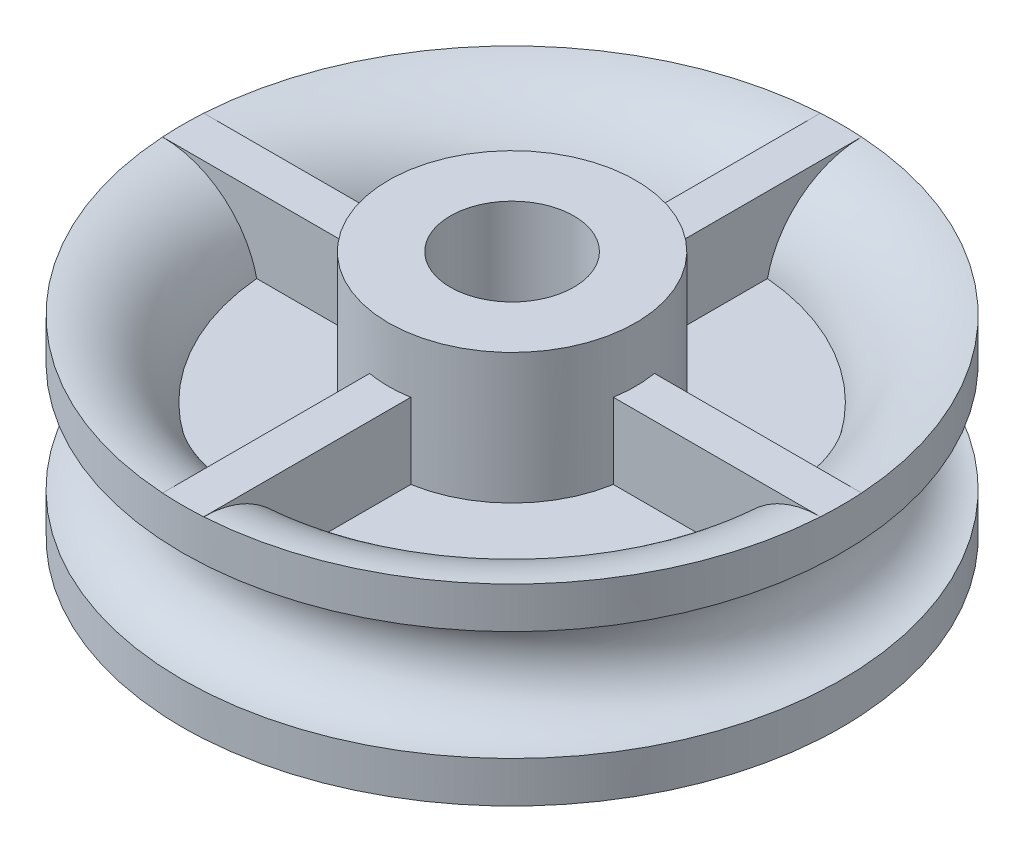
from build123d import *

# Parameters (mm, degrees)
RIB9_REACH        = 80.502
SKETCH5_WALL_W    = 189.003354934
SKETCH5_WALL_H    = 6
CIRPATTERN1_COUNT = 4


with BuildPart() as part:
    # Sketch1 → Revolve2 (revolve)
    with BuildSketch(Plane.XY, mode=Mode.PRIVATE) as revolve2_sk:
        with BuildLine():
            ThreePointArc((-56.342741935, -0.846438172), (-48.342741935, 7.153561828), (-56.342741935, 15.153561828))
            Line((-56.342741935, 15.153561828), (-56.342741935, 21.153561828))
            ThreePointArc((-56.342741935, 21.153561828), (-42.342741935, 7.153561828), (-56.342741935, -6.846438172))
            Line((-56.342741935, -6.846438172), (-56.342741935, -0.846438172))
        make_face()
        with BuildLine():
            Line((-17.342741935, -14.846438172), (-17.342741935, 26.153561828))
            Line((-17.342741935, 26.153561828), (-26.342741935, 26.153561828))
            Line((-26.342741935, 26.153561828), (-26.342741935, 21.153561828))
            Line((-26.342741935, 21.153561828), (-26.342741935, 18.153561828))
            Line((-26.342741935, 18.153561828), (-26.342741935, 10.153561828))
            Line((-26.342741935, 10.153561828), (-42.667947604, 10.153561828))
            ThreePointArc((-42.667947604, 10.153561828), (-42.342741935, 7.153561828), (-42.667947604, 4.153561828))
            Line((-42.667947604, 4.153561828), (-26.342741935, 4.153561828))
            Line((-26.342741935, 4.153561828), (-26.342741935, -3.846438172))
            Line((-26.342741935, -3.846438172), (-26.342741935, -6.846438172))
            Line((-26.342741935, -6.846438172), (-26.342741935, -14.846438172))
            Line((-26.342741935, -14.846438172), (-17.342741935, -14.846438172))
        make_face()
    revolve(revolve2_sk.sketch.rotate(Axis((-8.342741935, 57.152217742, 0), (0, -1, 0)), 270), axis=Axis((-8.342741935, 57.152217742, 0), (0, -1, 0)))

    # Sketch5 wall → Rib9 (add, up to next)
    with BuildSketch(Plane(origin=(-41.342741935, 21.153561828, 0), x_dir=(-1, 0, 0), z_dir=(0, -1, 0)), mode=Mode.PRIVATE) as rib9_sk1:
        Rectangle(SKETCH5_WALL_W, SKETCH5_WALL_H)
    rib9_tool1 = extrude(rib9_sk1.sketch, amount=RIB9_REACH, mode=Mode.PRIVATE) - part.part
    rib9 = rib9_tool1.solids().sort_by_distance((-41.342741935, 21.153561828, 0))[0]
    add(rib9)

    # CirPattern1: Rib9 ×4 about axis
    cirpattern1_axis = Axis((-8.342741935, 0, 0), (0, 1, 0))
    for i in range(1, CIRPATTERN1_COUNT):
        add(rib9.rotate(cirpattern1_axis, i * 360 / CIRPATTERN1_COUNT))

    # Mirror1: part across plane


with BuildPart() as part_1:
    add(part.part)
    add(part.part.mirror(Plane.ZX.offset(7.153561828)))


solid = part_1.part
